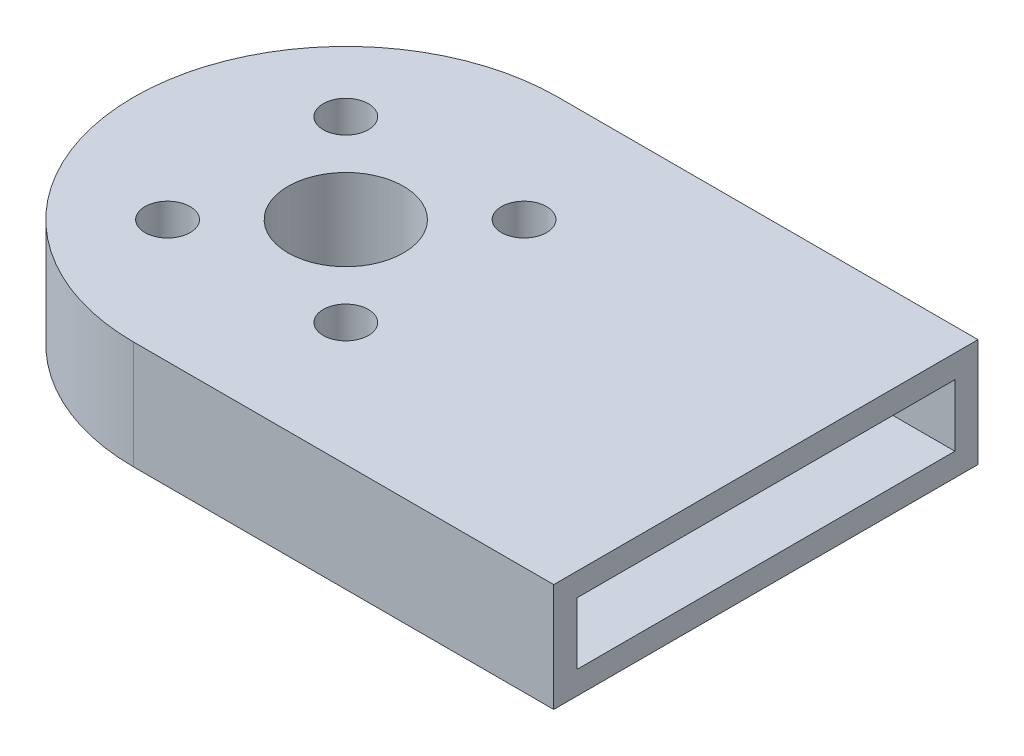
from build123d import *

# Parameters (mm, degrees)
SKETCH2_R           = 1.075
SKETCH2_R_2         = 2.75
BOSS_EXTRUDE1_DEPTH = 5.15
SHELL1_T            = -1.1


with BuildPart() as part:
    # Sketch2 → Boss-Extrude1 (new body)
    with BuildSketch(Plane(origin=(0, 0, 0), x_dir=(1, 0, 0), z_dir=(0, 1, 0))):
        with BuildLine():
            Line((0, 10.1), (20, 10.1))
            Line((20, 10.1), (20, -10.1))
            Line((20, -10.1), (0, -10.1))
            ThreePointArc((0, -10.1), (-10.1, 0), (0, 10.1))
        make_face()
        with Locations((-4.242640687, 4.242640687)):
            Circle(SKETCH2_R, mode=Mode.SUBTRACT)
        with Locations((4.242640687, 4.242640687)):
            Circle(SKETCH2_R, mode=Mode.SUBTRACT)
        with Locations((-4.242640687, -4.242640687)):
            Circle(SKETCH2_R, mode=Mode.SUBTRACT)
        with Locations((4.242640687, -4.242640687)):
            Circle(SKETCH2_R, mode=Mode.SUBTRACT)
        Circle(SKETCH2_R_2, mode=Mode.SUBTRACT)
    extrude(amount=BOSS_EXTRUDE1_DEPTH)

    # Shell1
    shell1_openings = [part.faces().sort_by_distance(p)[0] for p in [
        (20, 2.575, 0),
    ]]
    offset(amount=SHELL1_T, openings=shell1_openings)


solid = part.part
